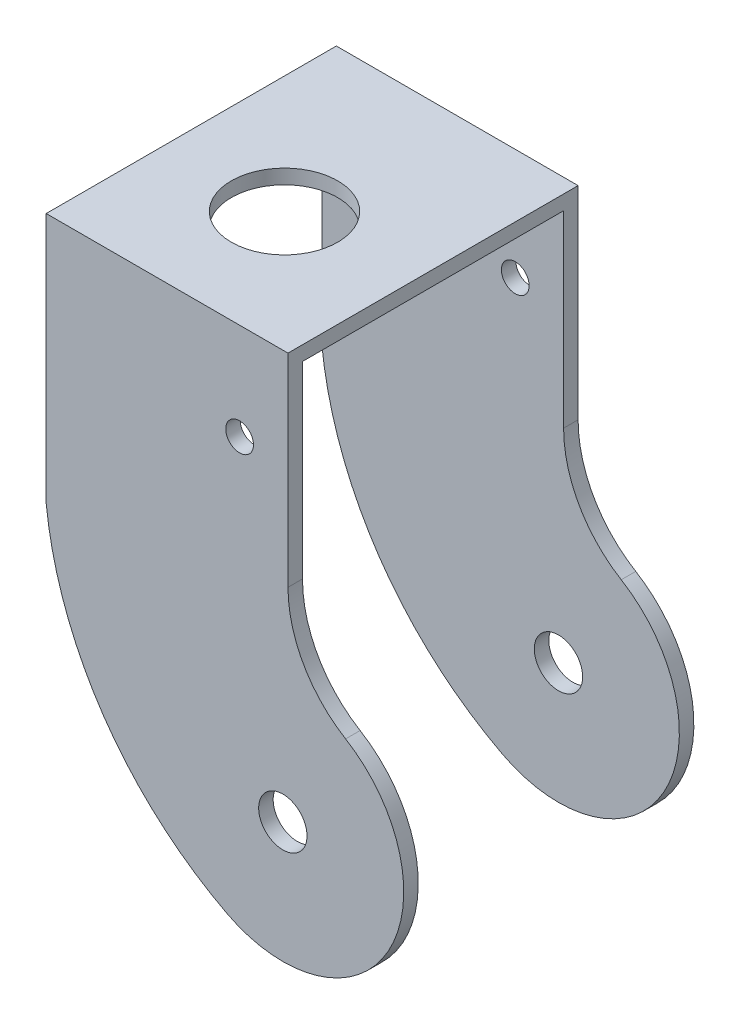
from build123d import *

# Parameters (mm, degrees)
SKETCH_1_R          = 5
SKETCH_1_R_2        = 2.870333843
EXTRUDE_1_DEPTH     = 60
SKETCH_2_W          = 54
SKETCH_2_H          = 139.687150663
CUT_EXTRUDE_1_DEPTH = 74.937741711
SKETCH_3_R          = 11
CUT_EXTRUDE_2_DEPTH = 70


with BuildPart() as part:
    # 草图1 → 凸台-拉伸1 (new body)
    with BuildSketch(Plane.XY):
        with BuildLine():
            Line((-24.281457554, 46.564371273), (-24.281457554, -5.37876517))
            ThreePointArc((-24.281457554, -5.37876517), (-12.44727906, -37.430517799), (13.107980321, -60.108510328))
            ThreePointArc((13.107980321, -60.108510328), (46.43701917, -50.207530875), (37.638484361, -16.570646211))
            ThreePointArc((37.638484361, -16.570646211), (28.903009587, -7.536360283), (25.718542446, 4.620366695))
            Line((25.718542446, 4.620366695), (25.718542446, 46.564371273))
            Line((25.718542446, 46.564371273), (-24.281457554, 46.564371273))
        make_face()
        with Locations((24.656284158, -37.935628727)):
            Circle(SKETCH_1_R, mode=Mode.SUBTRACT)
        with Locations((15.718542446, 26.564371273)):
            Circle(SKETCH_1_R_2, mode=Mode.SUBTRACT)
    extrude(amount=EXTRUDE_1_DEPTH)

    # 草图2 → 切除-拉伸1 (cut, through all)
    with BuildSketch(Plane.ZY.offset(24.281457554)):
        with Locations((30, -26.279204058)):
            Rectangle(SKETCH_2_W, SKETCH_2_H)
    extrude(amount=-CUT_EXTRUDE_1_DEPTH, mode=Mode.SUBTRACT)

    # 草图3 → 切除-拉伸2 (cut)
    with BuildSketch(Plane(origin=(0, 46.564371273, 0), x_dir=(1, 0, 0), z_dir=(0, 1, 0))):
        with Locations((0, -35)):
            Circle(SKETCH_3_R)
    extrude(amount=-CUT_EXTRUDE_2_DEPTH, mode=Mode.SUBTRACT)


solid = part.part
